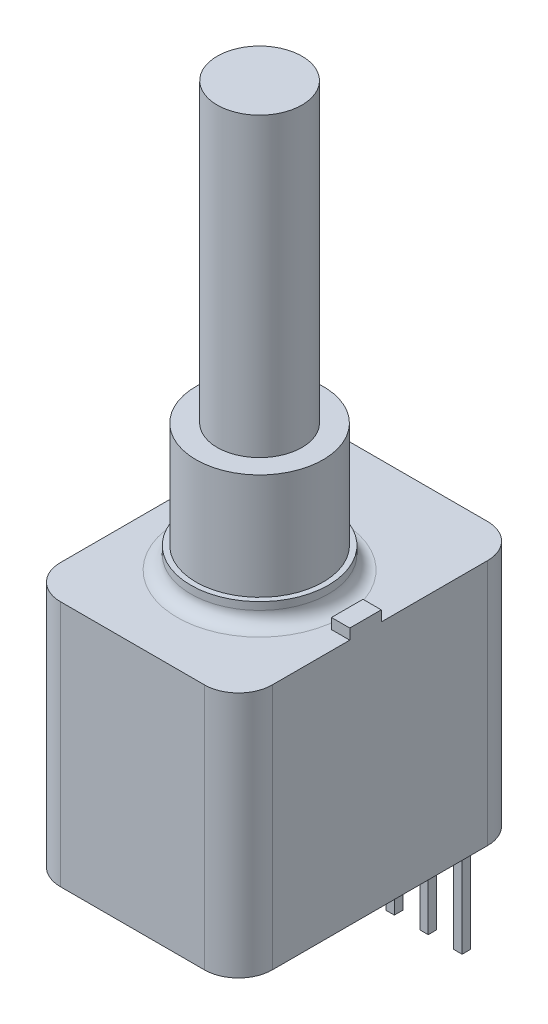
from build123d import *

# Parameters (mm, degrees)
SKETCH1_W               = 15.875
SKETCH1_H               = 21.21
BODY_DEPTH              = 18.5
SKETCH2_R               = 4.7625
EXTRUDE_3_8_32_DEPTH    = 9.53
SKETCH4_R               = 3.175
SHAFT_DEPTH             = 22.225
SKETCH5_R               = 5.15874
BOSS_DEPTH              = 1.5875
SKETCH6_W               = 1.3716
SKETCH6_H               = 2.36
ANTI_ROTATION_LUG_DEPTH = 0.7874
SKETCH7_W               = 0.635
SKETCH7_H               = 0.635
PINS_DEPTH              = 8.636
FILLET1_R               = 1.016
FILLET2_R               = 2.54


with BuildPart() as part:
    # Sketch1 → body (new body)
    with BuildSketch(Plane(origin=(0, 0, 0), x_dir=(1, 0, 0), z_dir=(0, 1, 0))):
        with Locations((0, 1.08)):
            Rectangle(SKETCH1_W, SKETCH1_H)
    extrude(amount=BODY_DEPTH)

    # Sketch2 → 3/8-32 (add)
    with BuildSketch(Plane(origin=(0, 18.5, 0), x_dir=(1, 0, 0), z_dir=(0, 1, 0))):
        Circle(SKETCH2_R)
    extrude(amount=EXTRUDE_3_8_32_DEPTH)

    # Sketch4 → shaft (add)
    with BuildSketch(Plane(origin=(0, 28.03, 0), x_dir=(1, 0, 0), z_dir=(0, 1, 0))):
        Circle(SKETCH4_R)
    extrude(amount=SHAFT_DEPTH)

    # Sketch5 → boss (add)
    with BuildSketch(Plane(origin=(0, 18.5, 0), x_dir=(1, 0, 0), z_dir=(0, 1, 0))):
        Circle(SKETCH5_R)
    extrude(amount=BOSS_DEPTH)

    # Sketch6 → anti-rotation lug (add)
    with BuildSketch(Plane(origin=(0, 18.5, 0), x_dir=(1, 0, 0), z_dir=(0, 1, 0))):
        with Locations((7.2517, 0)):
            Rectangle(SKETCH6_W, SKETCH6_H)
    extrude(amount=ANTI_ROTATION_LUG_DEPTH)

    # Sketch7 → pins (add)
    with BuildSketch(Plane.XZ):
        with Locations((-5.08, -10.0975)):
            Rectangle(SKETCH7_W, SKETCH7_H)
        with Locations((-2.54, -10.0975)):
            Rectangle(SKETCH7_W, SKETCH7_H)
        with Locations((0, -10.0975)):
            Rectangle(SKETCH7_W, SKETCH7_H)
        with Locations((2.54, -10.0975)):
            Rectangle(SKETCH7_W, SKETCH7_H)
        with Locations((5.08, -10.0975)):
            Rectangle(SKETCH7_W, SKETCH7_H)
    extrude(amount=PINS_DEPTH)

    # Fillet1
    fillet1_edges = [part.edges().sort_by_distance(p)[0] for p in [
        (-5.15874, 18.5, 0),
    ]]
    fillet(fillet1_edges, radius=FILLET1_R)

    # Fillet2
    fillet2_edges = [part.edges().sort_by_distance(p)[0] for p in [
        (7.9375, 9.25, 9.525),
        (-7.9375, 9.25, 9.525),
        (-7.9375, 9.25, -11.685),
        (7.9375, 9.25, -11.685),
    ]]
    fillet(fillet2_edges, radius=FILLET2_R)


solid = part.part
